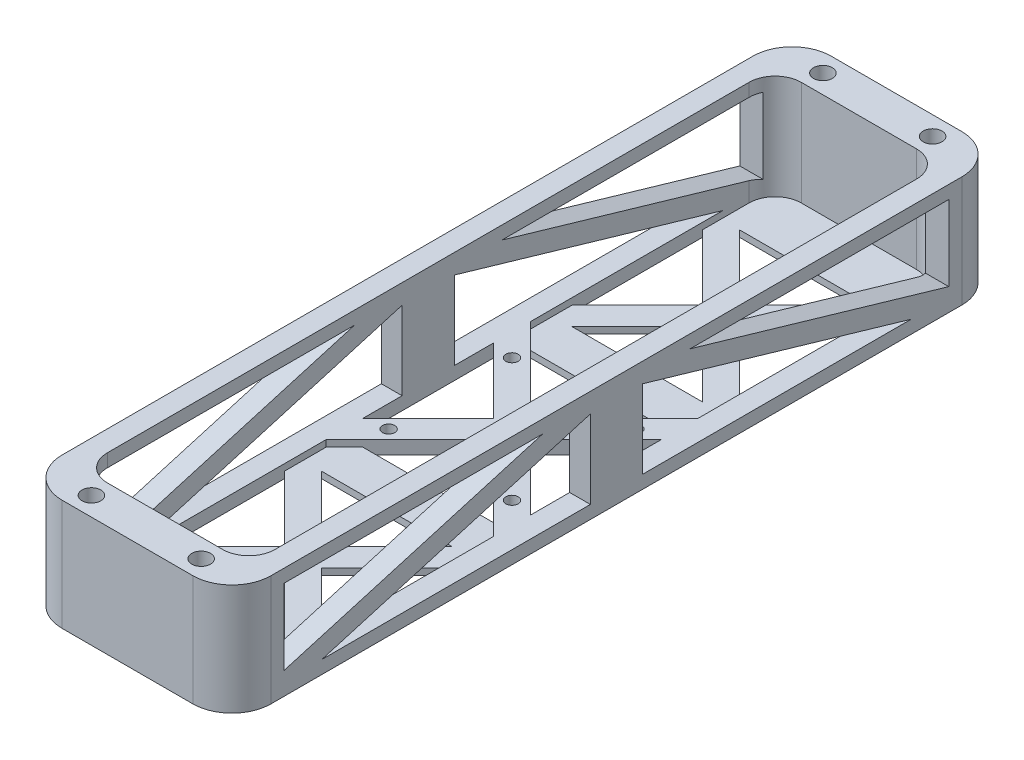
from build123d import *

# Parameters (mm, degrees)
SKETCH1_R            = 2.286
SKETCH1_R_2          = 1.5
BOSS_EXTRUDE1_DEPTH  = 1.5875
CUT_EXTRUDE1_REACH   = 145.693
SKETCH4_R            = 2.286
BOSS_EXTRUDE4_DEPTH  = 25.4
SKETCH16_R           = 1.5
BOSS_EXTRUDE6_DEPTH  = 1.5875
CUT_EXTRUDE13_DEPTH  = 23.8125
CUT_EXTRUDE15_REACH  = 166.863
CUT_EXTRUDE17_REACH  = 147.912
SKETCH20_W           = 50.8
SKETCH20_H           = 8.128
SKETCH20_W_2         = 8.128
SKETCH20_H_2         = 50.8
FILLET2_R            = 9.525
FILLET3_R            = 6.35
CUT_EXTRUDE18_DEPTH  = 118.872
BOSS_EXTRUDE7_DEPTH  = 1.5875
SKETCH23_W           = 5.034871939
SKETCH23_H           = 59.780256122
BOSS_EXTRUDE8_DEPTH  = 3.175
SKETCH24_W           = 59.780256122
SKETCH24_H           = 20.6375
BOSS_EXTRUDE9_DEPTH  = 5.034871939
SKETCH25_W           = 59.780256122
SKETCH25_H           = 20.6375
BOSS_EXTRUDE10_DEPTH = 5.034871939
CUT_EXTRUDE21_START  = -50.8
CUT_EXTRUDE21_DEPTH  = 50.8


with BuildPart() as part:
    # Sketch1 → Boss-Extrude1 (new body)
    with BuildSketch(Plane(origin=(0, 0, 0), x_dir=(1, 0, 0), z_dir=(0, 1, 0))):
        Polygon((-25.4, 101.6), (25.4, 101.6), (25.4, 25.4), (101.6, 25.4), (101.6, -25.4), (25.4, -25.4), (25.4, -101.6), (-25.4, -101.6), (-25.4, -25.4), (-101.6, -25.4), (-101.6, 25.4), (-25.4, 25.4), align=None)
        with Locations(Location((-13.335, 88.9, 0), (0, 0, 270))):
            Circle(SKETCH1_R, mode=Mode.SUBTRACT)
        with Locations(Location((13.335, 88.9, 0), (0, 0, 270))):
            Circle(SKETCH1_R, mode=Mode.SUBTRACT)
        with Locations(Location((-13.335, -88.9, 0), (0, 0, 270))):
            Circle(SKETCH1_R, mode=Mode.SUBTRACT)
        with Locations(Location((13.335, -88.9, 0), (0, 0, 270))):
            Circle(SKETCH1_R, mode=Mode.SUBTRACT)
        with Locations(Location((88.9, -13.335, 0), (0, 0, 270))):
            Circle(SKETCH1_R, mode=Mode.SUBTRACT)
        with Locations(Location((88.9, 13.335, 0), (0, 0, 270))):
            Circle(SKETCH1_R, mode=Mode.SUBTRACT)
        with Locations(Location((-88.9, 13.335, 0), (0, 0, 270))):
            Circle(SKETCH1_R, mode=Mode.SUBTRACT)
        with Locations(Location((-88.9, -13.335, 0), (0, 0, 270))):
            Circle(SKETCH1_R, mode=Mode.SUBTRACT)
        with Locations(Location((-15, 15, 0), (0, 0, 270))):
            Circle(SKETCH1_R_2, mode=Mode.SUBTRACT)
        with Locations(Location((15, 15, 0), (0, 0, 270))):
            Circle(SKETCH1_R_2, mode=Mode.SUBTRACT)
        with Locations(Location((15, -15, 0), (0, 0, 270))):
            Circle(SKETCH1_R_2, mode=Mode.SUBTRACT)
        with Locations(Location((-15, -15, 0), (0, 0, 270))):
            Circle(SKETCH1_R_2, mode=Mode.SUBTRACT)
    extrude(amount=BOSS_EXTRUDE1_DEPTH)

    # Sketch3 → Cut-Extrude1 (cut, up to next)
    with BuildSketch(Plane(origin=(0, 1.5875, 0), x_dir=(1, 0, 0), z_dir=(0, 1, 0)), mode=Mode.PRIVATE) as cut_extrude1_sk1:
        Polygon((15.875, 71.165128061), (0, 55.290128061), (-15.875, 71.165128061), align=None)
    cut_extrude1_tool1 = extrude(cut_extrude1_sk1.sketch, amount=-CUT_EXTRUDE1_REACH, mode=Mode.PRIVATE) & part.part
    # Sketch3 → Cut-Extrude1 (cut, up to next)
    with BuildSketch(Plane(origin=(0, 1.5875, 0), x_dir=(1, 0, 0), z_dir=(0, 1, 0)), mode=Mode.PRIVATE) as cut_extrude1_sk2:
        Polygon((-20.365128061, 66.675), (-4.490128061, 50.8), (-20.365128061, 34.925), align=None)
    cut_extrude1_tool2 = extrude(cut_extrude1_sk2.sketch, amount=-CUT_EXTRUDE1_REACH, mode=Mode.PRIVATE) & part.part
    # Sketch3 → Cut-Extrude1 (cut, up to next)
    with BuildSketch(Plane(origin=(0, 1.5875, 0), x_dir=(1, 0, 0), z_dir=(0, 1, 0)), mode=Mode.PRIVATE) as cut_extrude1_sk3:
        Polygon((-15.875, 30.434871939), (0, 46.309871939), (15.875, 30.434871939), align=None)
    cut_extrude1_tool3 = extrude(cut_extrude1_sk3.sketch, amount=-CUT_EXTRUDE1_REACH, mode=Mode.PRIVATE) & part.part
    # Sketch3 → Cut-Extrude1 (cut, up to next)
    with BuildSketch(Plane(origin=(0, 1.5875, 0), x_dir=(1, 0, 0), z_dir=(0, 1, 0)), mode=Mode.PRIVATE) as cut_extrude1_sk4:
        Polygon((20.365128061, 34.925), (4.490128061, 50.8), (20.365128061, 66.675), align=None)
    cut_extrude1_tool4 = extrude(cut_extrude1_sk4.sketch, amount=-CUT_EXTRUDE1_REACH, mode=Mode.PRIVATE) & part.part
    # Sketch3 → Cut-Extrude1 (cut, up to next)
    with BuildSketch(Plane(origin=(0, 1.5875, 0), x_dir=(1, 0, 0), z_dir=(0, 1, 0)), mode=Mode.PRIVATE) as cut_extrude1_sk5:
        Polygon((-34.925, 20.365128061), (-50.8, 4.490128061), (-66.675, 20.365128061), align=None)
    cut_extrude1_tool5 = extrude(cut_extrude1_sk5.sketch, amount=-CUT_EXTRUDE1_REACH, mode=Mode.PRIVATE) & part.part
    # Sketch3 → Cut-Extrude1 (cut, up to next)
    with BuildSketch(Plane(origin=(0, 1.5875, 0), x_dir=(1, 0, 0), z_dir=(0, 1, 0)), mode=Mode.PRIVATE) as cut_extrude1_sk6:
        Polygon((-71.165128061, 15.875), (-55.290128061, 0), (-71.165128061, -15.875), align=None)
    cut_extrude1_tool6 = extrude(cut_extrude1_sk6.sketch, amount=-CUT_EXTRUDE1_REACH, mode=Mode.PRIVATE) & part.part
    # Sketch3 → Cut-Extrude1 (cut, up to next)
    with BuildSketch(Plane(origin=(0, 1.5875, 0), x_dir=(1, 0, 0), z_dir=(0, 1, 0)), mode=Mode.PRIVATE) as cut_extrude1_sk7:
        Polygon((-66.675, -20.365128061), (-50.8, -4.490128061), (-34.925, -20.365128061), align=None)
    cut_extrude1_tool7 = extrude(cut_extrude1_sk7.sketch, amount=-CUT_EXTRUDE1_REACH, mode=Mode.PRIVATE) & part.part
    # Sketch3 → Cut-Extrude1 (cut, up to next)
    with BuildSketch(Plane(origin=(0, 1.5875, 0), x_dir=(1, 0, 0), z_dir=(0, 1, 0)), mode=Mode.PRIVATE) as cut_extrude1_sk8:
        Polygon((-30.434871939, -15.875), (-46.309871939, 0), (-30.434871939, 15.875), align=None)
    cut_extrude1_tool8 = extrude(cut_extrude1_sk8.sketch, amount=-CUT_EXTRUDE1_REACH, mode=Mode.PRIVATE) & part.part
    # Sketch3 → Cut-Extrude1 (cut, up to next)
    with BuildSketch(Plane(origin=(0, 1.5875, 0), x_dir=(1, 0, 0), z_dir=(0, 1, 0)), mode=Mode.PRIVATE) as cut_extrude1_sk9:
        Polygon((30.434871939, 15.875), (46.309871939, 0), (30.434871939, -15.875), align=None)
    cut_extrude1_tool9 = extrude(cut_extrude1_sk9.sketch, amount=-CUT_EXTRUDE1_REACH, mode=Mode.PRIVATE) & part.part
    # Sketch3 → Cut-Extrude1 (cut, up to next)
    with BuildSketch(Plane(origin=(0, 1.5875, 0), x_dir=(1, 0, 0), z_dir=(0, 1, 0)), mode=Mode.PRIVATE) as cut_extrude1_sk10:
        Polygon((66.675, 20.365128061), (50.8, 4.490128061), (34.925, 20.365128061), align=None)
    cut_extrude1_tool10 = extrude(cut_extrude1_sk10.sketch, amount=-CUT_EXTRUDE1_REACH, mode=Mode.PRIVATE) & part.part
    # Sketch3 → Cut-Extrude1 (cut, up to next)
    with BuildSketch(Plane(origin=(0, 1.5875, 0), x_dir=(1, 0, 0), z_dir=(0, 1, 0)), mode=Mode.PRIVATE) as cut_extrude1_sk11:
        Polygon((71.165128061, -15.875), (55.290128061, 0), (71.165128061, 15.875), align=None)
    cut_extrude1_tool11 = extrude(cut_extrude1_sk11.sketch, amount=-CUT_EXTRUDE1_REACH, mode=Mode.PRIVATE) & part.part
    # Sketch3 → Cut-Extrude1 (cut, up to next)
    with BuildSketch(Plane(origin=(0, 1.5875, 0), x_dir=(1, 0, 0), z_dir=(0, 1, 0)), mode=Mode.PRIVATE) as cut_extrude1_sk12:
        Polygon((34.925, -20.365128061), (50.8, -4.490128061), (66.675, -20.365128061), align=None)
    cut_extrude1_tool12 = extrude(cut_extrude1_sk12.sketch, amount=-CUT_EXTRUDE1_REACH, mode=Mode.PRIVATE) & part.part
    # Sketch3 → Cut-Extrude1 (cut, up to next)
    with BuildSketch(Plane(origin=(0, 1.5875, 0), x_dir=(1, 0, 0), z_dir=(0, 1, 0)), mode=Mode.PRIVATE) as cut_extrude1_sk13:
        Polygon((15.875, -30.434871939), (0, -46.309871939), (-15.875, -30.434871939), align=None)
    cut_extrude1_tool13 = extrude(cut_extrude1_sk13.sketch, amount=-CUT_EXTRUDE1_REACH, mode=Mode.PRIVATE) & part.part
    # Sketch3 → Cut-Extrude1 (cut, up to next)
    with BuildSketch(Plane(origin=(0, 1.5875, 0), x_dir=(1, 0, 0), z_dir=(0, 1, 0)), mode=Mode.PRIVATE) as cut_extrude1_sk14:
        Polygon((-20.365128061, -34.925), (-4.490128061, -50.8), (-20.365128061, -66.675), align=None)
    cut_extrude1_tool14 = extrude(cut_extrude1_sk14.sketch, amount=-CUT_EXTRUDE1_REACH, mode=Mode.PRIVATE) & part.part
    # Sketch3 → Cut-Extrude1 (cut, up to next)
    with BuildSketch(Plane(origin=(0, 1.5875, 0), x_dir=(1, 0, 0), z_dir=(0, 1, 0)), mode=Mode.PRIVATE) as cut_extrude1_sk15:
        Polygon((20.365128061, -66.675), (4.490128061, -50.8), (20.365128061, -34.925), align=None)
    cut_extrude1_tool15 = extrude(cut_extrude1_sk15.sketch, amount=-CUT_EXTRUDE1_REACH, mode=Mode.PRIVATE) & part.part
    # Sketch3 → Cut-Extrude1 (cut, up to next)
    with BuildSketch(Plane(origin=(0, 1.5875, 0), x_dir=(1, 0, 0), z_dir=(0, 1, 0)), mode=Mode.PRIVATE) as cut_extrude1_sk16:
        Polygon((-15.875, -71.165128061), (0, -55.290128061), (15.875, -71.165128061), align=None)
    cut_extrude1_tool16 = extrude(cut_extrude1_sk16.sketch, amount=-CUT_EXTRUDE1_REACH, mode=Mode.PRIVATE) & part.part
    # Sketch3 → Cut-Extrude1 (cut, up to next)
    with BuildSketch(Plane(origin=(0, 1.5875, 0), x_dir=(1, 0, 0), z_dir=(0, 1, 0)), mode=Mode.PRIVATE) as cut_extrude1_sk17:
        Polygon((0, 4.490128061), (-15.875, 20.365128061), (15.875, 20.365128061), align=None)
    cut_extrude1_tool17 = extrude(cut_extrude1_sk17.sketch, amount=-CUT_EXTRUDE1_REACH, mode=Mode.PRIVATE) & part.part
    # Sketch3 → Cut-Extrude1 (cut, up to next)
    with BuildSketch(Plane(origin=(0, 1.5875, 0), x_dir=(1, 0, 0), z_dir=(0, 1, 0)), mode=Mode.PRIVATE) as cut_extrude1_sk18:
        Polygon((-4.490128061, 0), (-20.365128061, -15.875), (-20.365128061, 15.875), align=None)
    cut_extrude1_tool18 = extrude(cut_extrude1_sk18.sketch, amount=-CUT_EXTRUDE1_REACH, mode=Mode.PRIVATE) & part.part
    # Sketch3 → Cut-Extrude1 (cut, up to next)
    with BuildSketch(Plane(origin=(0, 1.5875, 0), x_dir=(1, 0, 0), z_dir=(0, 1, 0)), mode=Mode.PRIVATE) as cut_extrude1_sk19:
        Polygon((-15.875, -20.365128061), (0, -4.490128061), (15.875, -20.365128061), align=None)
    cut_extrude1_tool19 = extrude(cut_extrude1_sk19.sketch, amount=-CUT_EXTRUDE1_REACH, mode=Mode.PRIVATE) & part.part
    # Sketch3 → Cut-Extrude1 (cut, up to next)
    with BuildSketch(Plane(origin=(0, 1.5875, 0), x_dir=(1, 0, 0), z_dir=(0, 1, 0)), mode=Mode.PRIVATE) as cut_extrude1_sk20:
        Polygon((20.365128061, 15.875), (20.365128061, -15.875), (4.490128061, 0), align=None)
    cut_extrude1_tool20 = extrude(cut_extrude1_sk20.sketch, amount=-CUT_EXTRUDE1_REACH, mode=Mode.PRIVATE) & part.part
    add(cut_extrude1_tool1.solids().sort_by_distance((0, 1.5875, -65.873461))[0], mode=Mode.SUBTRACT)
    add(cut_extrude1_tool2.solids().sort_by_distance((-15.073461, 1.5875, -50.8))[0], mode=Mode.SUBTRACT)
    add(cut_extrude1_tool3.solids().sort_by_distance((0, 1.5875, -35.726539))[0], mode=Mode.SUBTRACT)
    add(cut_extrude1_tool4.solids().sort_by_distance((15.073461, 1.5875, -50.8))[0], mode=Mode.SUBTRACT)
    add(cut_extrude1_tool5.solids().sort_by_distance((-50.8, 1.5875, -15.073461))[0], mode=Mode.SUBTRACT)
    add(cut_extrude1_tool6.solids().sort_by_distance((-65.873461, 1.5875, 0))[0], mode=Mode.SUBTRACT)
    add(cut_extrude1_tool7.solids().sort_by_distance((-50.8, 1.5875, 15.073461))[0], mode=Mode.SUBTRACT)
    add(cut_extrude1_tool8.solids().sort_by_distance((-35.726539, 1.5875, 0))[0], mode=Mode.SUBTRACT)
    add(cut_extrude1_tool9.solids().sort_by_distance((35.726539, 1.5875, 0))[0], mode=Mode.SUBTRACT)
    add(cut_extrude1_tool10.solids().sort_by_distance((50.8, 1.5875, -15.073461))[0], mode=Mode.SUBTRACT)
    add(cut_extrude1_tool11.solids().sort_by_distance((65.873461, 1.5875, 0))[0], mode=Mode.SUBTRACT)
    add(cut_extrude1_tool12.solids().sort_by_distance((50.8, 1.5875, 15.073461))[0], mode=Mode.SUBTRACT)
    add(cut_extrude1_tool13.solids().sort_by_distance((0, 1.5875, 35.726539))[0], mode=Mode.SUBTRACT)
    add(cut_extrude1_tool14.solids().sort_by_distance((-15.073461, 1.5875, 50.8))[0], mode=Mode.SUBTRACT)
    add(cut_extrude1_tool15.solids().sort_by_distance((15.073461, 1.5875, 50.8))[0], mode=Mode.SUBTRACT)
    add(cut_extrude1_tool16.solids().sort_by_distance((0, 1.5875, 65.873461))[0], mode=Mode.SUBTRACT)
    add(cut_extrude1_tool17.solids().sort_by_distance((0, 1.5875, -15.073461))[0], mode=Mode.SUBTRACT)
    add(cut_extrude1_tool18.solids().sort_by_distance((-15.073461, 1.5875, 0))[0], mode=Mode.SUBTRACT)
    add(cut_extrude1_tool19.solids().sort_by_distance((0, 1.5875, 15.073461))[0], mode=Mode.SUBTRACT)
    add(cut_extrude1_tool20.solids().sort_by_distance((15.073461, 1.5875, 0))[0], mode=Mode.SUBTRACT)

    # Sketch4 → Boss-Extrude4 (add)
    with BuildSketch(Plane(origin=(0, 1.5875, 0), x_dir=(1, 0, 0), z_dir=(0, 1, 0))):
        Polygon((-93.472, 25.4), (-93.472, 13.335), (-93.472, -13.335), (-93.472, -25.4), (-84.328, -25.4), (-25.4, -25.4), (-25.4, -84.328), (-25.4, -93.472), (-13.335, -93.472), (13.335, -93.472), (25.4, -93.472), (25.4, -84.328), (25.4, -25.4), (84.328, -25.4), (93.472, -25.4), (93.472, -13.335), (93.472, 13.335), (93.472, 25.4), (84.328, 25.4), (25.4, 25.4), (25.4, 84.328), (25.4, 93.472), (13.335, 93.472), (-13.335, 93.472), (-25.4, 93.472), (-25.4, 84.328), (-25.4, 25.4), (-84.328, 25.4), align=None)
        with Locations(Location((-13.335, -88.9, 0), (0, 0, 270))):
            Circle(SKETCH4_R, mode=Mode.SUBTRACT)
        with Locations(Location((-88.9, -13.335, 0), (0, 0, 270))):
            Circle(SKETCH4_R, mode=Mode.SUBTRACT)
        with Locations(Location((13.335, -88.9, 0), (0, 0, 270))):
            Circle(SKETCH4_R, mode=Mode.SUBTRACT)
        with Locations(Location((88.9, -13.335, 0), (0, 0, 270))):
            Circle(SKETCH4_R, mode=Mode.SUBTRACT)
        with Locations(Location((-88.9, 13.335, 0), (0, 0, 270))):
            Circle(SKETCH4_R, mode=Mode.SUBTRACT)
        with Locations(Location((-13.335, 88.9, 0), (0, 0, 270))):
            Circle(SKETCH4_R, mode=Mode.SUBTRACT)
        Polygon((84.328, 20.365128061), (84.328, 13.335), (84.328, -13.335), (84.328, -20.365128061), (66.675, -20.365128061), (34.925, -20.365128061), (25.4, -20.365128061), (20.365128061, -20.365128061), (20.365128061, -25.4), (20.365128061, -34.925), (20.365128061, -66.675), (20.365128061, -84.328), (13.335, -84.328), (-13.335, -84.328), (-20.365128061, -84.328), (-20.365128061, -66.675), (-20.365128061, -34.925), (-20.365128061, -25.4), (-20.365128061, -20.365128061), (-25.4, -20.365128061), (-34.925, -20.365128061), (-66.675, -20.365128061), (-84.328, -20.365128061), (-84.328, -13.335), (-84.328, 13.335), (-84.328, 20.365128061), (-66.675, 20.365128061), (-34.925, 20.365128061), (-25.4, 20.365128061), (-20.365128061, 20.365128061), (-20.365128061, 25.4), (-20.365128061, 34.925), (-20.365128061, 66.675), (-20.365128061, 84.328), (-13.335, 84.328), (13.335, 84.328), (20.365128061, 84.328), (20.365128061, 66.675), (20.365128061, 34.925), (20.365128061, 25.4), (20.365128061, 20.365128061), (25.4, 20.365128061), (34.925, 20.365128061), (66.675, 20.365128061), align=None, mode=Mode.SUBTRACT)
        with Locations(Location((88.9, 13.335, 0), (0, 0, 270))):
            Circle(SKETCH4_R, mode=Mode.SUBTRACT)
        with Locations(Location((13.335, 88.9, 0), (0, 0, 270))):
            Circle(SKETCH4_R, mode=Mode.SUBTRACT)
    extrude(amount=BOSS_EXTRUDE4_DEPTH)

    # Sketch16 → Boss-Extrude6 (add)
    with BuildSketch(Plane(origin=(0, 1.5875, 0), x_dir=(1, 0, 0), z_dir=(0, 1, 0))):
        Polygon((20.365128061, 24.855256121), (15.875, 20.365128061), (0, 4.490128061), (-15.875, 20.365128061), (-20.365128061, 24.855256121), (-20.365128061, 20.365128061), (-24.855256121, 20.365128061), (-20.365128061, 15.875), (-4.490128061, 0), (-20.365128061, -15.875), (-24.855256121, -20.365128061), (-20.365128061, -20.365128061), (-20.365128061, -24.855256121), (-15.875, -20.365128061), (0, -4.490128061), (15.875, -20.365128061), (20.365128061, -24.855256121), (20.365128061, -20.365128061), (24.855256121, -20.365128061), (20.365128061, -15.875), (4.490128061, 0), (20.365128061, 15.875), (24.855256121, 20.365128061), (20.365128061, 20.365128061), align=None)
        with Locations((-15, -15)):
            Circle(SKETCH16_R, mode=Mode.SUBTRACT)
        with Locations((15, -15)):
            Circle(SKETCH16_R, mode=Mode.SUBTRACT)
        with Locations((-15, 15)):
            Circle(SKETCH16_R, mode=Mode.SUBTRACT)
        with Locations((15, 15)):
            Circle(SKETCH16_R, mode=Mode.SUBTRACT)
    extrude(amount=BOSS_EXTRUDE6_DEPTH)

    # Sketch17 → Cut-Extrude13 (cut)
    with BuildSketch(Plane(origin=(0, 26.9875, 0), x_dir=(1, 0, 0), z_dir=(0, 1, 0))):
        Polygon((-25.4, 25.4), (-29.890128061, 25.4), (-24.855256121, 20.365128061), (-20.365128061, 20.365128061), (-20.365128061, 24.855256121), (-25.4, 29.890128061), align=None)
        Polygon((20.365128061, 20.365128061), (24.855256121, 20.365128061), (29.890128061, 25.4), (25.4, 25.4), (25.4, 29.890128061), (20.365128061, 24.855256121), align=None)
        Polygon((20.365128061, -24.855256121), (25.4, -29.890128061), (25.4, -25.4), (29.890128061, -25.4), (24.855256121, -20.365128061), (20.365128061, -20.365128061), align=None)
        Polygon((-29.890128061, -25.4), (-25.4, -25.4), (-25.4, -29.890128061), (-20.365128061, -24.855256121), (-20.365128061, -20.365128061), (-24.855256121, -20.365128061), align=None)
        Polygon((-24.855256121, 20.365128061), (-29.890128061, 25.4), (-29.890128061, 20.365128061), align=None)
        Polygon((-20.365128061, 29.890128061), (-25.4, 29.890128061), (-20.365128061, 24.855256121), align=None)
        Polygon((20.365128061, 29.890128061), (20.365128061, 24.855256121), (25.4, 29.890128061), align=None)
        Polygon((29.890128061, 25.4), (24.855256121, 20.365128061), (29.890128061, 20.365128061), align=None)
        Polygon((24.855256121, -20.365128061), (29.890128061, -25.4), (29.890128061, -20.365128061), align=None)
        Polygon((20.365128061, -29.890128061), (25.4, -29.890128061), (20.365128061, -24.855256121), align=None)
        Polygon((-20.365128061, -24.855256121), (-25.4, -29.890128061), (-20.365128061, -29.890128061), align=None)
        Polygon((-29.890128061, -20.365128061), (-29.890128061, -25.4), (-24.855256121, -20.365128061), align=None)
    extrude(amount=-CUT_EXTRUDE13_DEPTH, mode=Mode.SUBTRACT)

    # Cut-Extrude15: up to this face of the body (flat: up to its plane)
    cut_extrude15_end = Plane(part.part.faces().sort_by_distance((61.668110408, 13.302359509, -25.4))[0])
    # Sketch18 → Cut-Extrude15 (cut, up to the picked face)
    with BuildSketch(Plane.XY.offset(25.4), mode=Mode.PRIVATE) as cut_extrude15_sk1:
        with BuildLine():
            add(Edge.make_bspline(
                [(-77.978, 26.9875), (-53.933199385, 9.774034089), (-29.890128061, 3.175)],
                knots=[0, 0, 0, 0.308317682, 0.308317682, 0.308317682], degree=2))
            Line((-29.890128061, 3.175), (-29.890128061, 26.9875))
            Line((-29.890128061, 26.9875), (-77.978, 26.9875))
        make_face()
    cut_extrude15_tool1 = split(extrude(cut_extrude15_sk1.sketch, amount=-CUT_EXTRUDE15_REACH, mode=Mode.PRIVATE), bisect_by=cut_extrude15_end, keep=Keep.BOTH, mode=Mode.PRIVATE)
    cut_extrude15 = cut_extrude15_tool1.solids().sort_by(Axis((-46.956117, 18.399328, 25.4), (0, 0, -1)))[0]
    add(cut_extrude15, mode=Mode.SUBTRACT)

    # Sketch20 → Cut-Extrude17 (cut, up to next)
    with BuildSketch(Plane(origin=(0, 1.5875, 0), x_dir=(1, 0, 0), z_dir=(0, 1, 0)), mode=Mode.PRIVATE) as cut_extrude17_sk1:
        with Locations((0, 97.536)):
            Rectangle(SKETCH20_W, SKETCH20_H)
    cut_extrude17_tool1 = extrude(cut_extrude17_sk1.sketch, amount=-CUT_EXTRUDE17_REACH, mode=Mode.PRIVATE) & part.part
    # Sketch20 → Cut-Extrude17 (cut, up to next)
    with BuildSketch(Plane(origin=(0, 1.5875, 0), x_dir=(1, 0, 0), z_dir=(0, 1, 0)), mode=Mode.PRIVATE) as cut_extrude17_sk2:
        with Locations((-97.536, 0)):
            Rectangle(SKETCH20_W_2, SKETCH20_H_2)
    cut_extrude17_tool2 = extrude(cut_extrude17_sk2.sketch, amount=-CUT_EXTRUDE17_REACH, mode=Mode.PRIVATE) & part.part
    # Sketch20 → Cut-Extrude17 (cut, up to next)
    with BuildSketch(Plane(origin=(0, 1.5875, 0), x_dir=(1, 0, 0), z_dir=(0, 1, 0)), mode=Mode.PRIVATE) as cut_extrude17_sk3:
        with Locations((0, -97.536)):
            Rectangle(SKETCH20_W, SKETCH20_H)
    cut_extrude17_tool3 = extrude(cut_extrude17_sk3.sketch, amount=-CUT_EXTRUDE17_REACH, mode=Mode.PRIVATE) & part.part
    # Sketch20 → Cut-Extrude17 (cut, up to next)
    with BuildSketch(Plane(origin=(0, 1.5875, 0), x_dir=(1, 0, 0), z_dir=(0, 1, 0)), mode=Mode.PRIVATE) as cut_extrude17_sk4:
        with Locations((97.536, 0)):
            Rectangle(SKETCH20_W_2, SKETCH20_H_2)
    cut_extrude17_tool4 = extrude(cut_extrude17_sk4.sketch, amount=-CUT_EXTRUDE17_REACH, mode=Mode.PRIVATE) & part.part
    add(cut_extrude17_tool1.solids().sort_by_distance((0, 1.5875, -97.536))[0], mode=Mode.SUBTRACT)
    add(cut_extrude17_tool2.solids().sort_by_distance((-97.536, 1.5875, 0))[0], mode=Mode.SUBTRACT)
    add(cut_extrude17_tool3.solids().sort_by_distance((0, 1.5875, 97.536))[0], mode=Mode.SUBTRACT)
    add(cut_extrude17_tool4.solids().sort_by_distance((97.536, 1.5875, 0))[0], mode=Mode.SUBTRACT)

    # Fillet2
    fillet2_edges = [part.edges().sort_by_distance(p)[0] for p in [
        (-25.4, 13.49375, 93.472),
        (25.4, 13.49375, 93.472),
        (93.472, 13.49375, 25.4),
        (93.472, 13.49375, -25.4),
        (25.4, 13.49375, -93.472),
        (-25.4, 13.49375, -93.472),
        (-93.472, 13.49375, -25.4),
        (-93.472, 13.49375, 25.4),
    ]]
    fillet(fillet2_edges, radius=FILLET2_R)

    # Fillet3
    fillet3_edges = [part.edges().sort_by_distance(p)[0] for p in [
        (84.328, 14.2875, -20.365128061),
        (84.328, 14.2875, 20.365128061),
        (20.365128061, 14.2875, 84.328),
        (-20.365128061, 14.2875, 84.328),
        (-84.328, 14.2875, 20.365128061),
        (-84.328, 14.2875, -20.365128061),
        (-20.365128061, 14.2875, -84.328),
        (20.365128061, 14.2875, -84.328),
    ]]
    fillet(fillet3_edges, radius=FILLET3_R)

    # Mirror1: Cut-Extrude15 across plane
    add(cut_extrude15.mirror(Plane(origin=(0, 0, 0), x_dir=(0, 0, 1), z_dir=(1, 0, 0))), mode=Mode.SUBTRACT)

    # Sketch21 → Cut-Extrude18 (cut)
    with BuildSketch(Plane.XY.offset(93.472)):
        with BuildLine():
            Line((93.472, 26.9875), (83.947, 26.9875))
            Line((83.947, 26.9875), (77.978, 26.9875))
            add(Edge.make_bspline(
                [(77.978, 26.9875), (53.933199385, 9.774034089), (29.890128061, 3.175)],
                knots=[0, 0, 0, 1, 1, 1], degree=2))
            Line((29.890128061, 3.175), (25.4, 3.175))
            Line((25.4, 3.175), (25.4, 0))
            Line((25.4, 0), (83.947, 0))
            Line((83.947, 0), (93.472, 0))
            Line((93.472, 0), (93.472, 26.9875))
        make_face()
        with BuildLine():
            Line((-83.947, 26.9875), (-93.472, 26.9875))
            Line((-93.472, 26.9875), (-93.472, 0))
            Line((-93.472, 0), (-83.947, 0))
            Line((-83.947, 0), (-25.4, 0))
            Line((-25.4, 0), (-25.4, 3.175))
            Line((-25.4, 3.175), (-29.890128061, 3.175))
            add(Edge.make_bspline(
                [(-29.890128061, 3.175), (-53.933199385, 9.774034089), (-77.978, 26.9875)],
                knots=[0, 0, 0, 1, 1, 1], degree=2))
            Line((-77.978, 26.9875), (-83.947, 26.9875))
        make_face()
    extrude(amount=-CUT_EXTRUDE18_DEPTH, mode=Mode.SUBTRACT)

    # Sketch22 → Boss-Extrude7 (add)
    with BuildSketch(Plane(origin=(0, 1.5875, 0), x_dir=(1, 0, 0), z_dir=(0, 1, 0))):
        Polygon((25.4, -20.365128061), (25.4, 20.365128061), (24.855256121, 20.365128061), (20.365128061, 15.875), (20.365128061, -15.875), (24.855256121, -20.365128061), align=None)
        Polygon((-25.4, 20.365128061), (-25.4, -20.365128061), (-24.855256121, -20.365128061), (-20.365128061, -15.875), (-20.365128061, 15.875), (-24.855256121, 20.365128061), align=None)
    extrude(amount=BOSS_EXTRUDE7_DEPTH)

    # Sketch23 → Boss-Extrude8 (add)
    with BuildSketch(Plane(origin=(0, 3.175, 0), x_dir=(1, 0, 0), z_dir=(0, 1, 0))):
        with Locations((22.88256403, 0)):
            Rectangle(SKETCH23_W, SKETCH23_H)
        with Locations((-22.88256403, 0)):
            Rectangle(SKETCH23_W, SKETCH23_H)
    extrude(amount=BOSS_EXTRUDE8_DEPTH)

    # Sketch24 → Boss-Extrude9 (add)
    with BuildSketch(Plane.ZY.offset(25.4)):
        with Locations((0, 16.66875)):
            Rectangle(SKETCH24_W, SKETCH24_H)
    extrude(amount=-BOSS_EXTRUDE9_DEPTH)

    # Sketch25 → Boss-Extrude10 (add)
    with BuildSketch(Plane(origin=(25.4, 0, 0), x_dir=(0, 0, -1), z_dir=(1, 0, 0))):
        with Locations((0, 16.66875)):
            Rectangle(SKETCH25_W, SKETCH25_H)
    extrude(amount=-BOSS_EXTRUDE10_DEPTH)

    # Sketch28 → Cut-Extrude21 (cut)
    with BuildSketch(Plane.ZY.offset(25.4).offset(CUT_EXTRUDE21_START)):
        Polygon((-80.772, 23.8125), (-80.772, 5.46568924), (-17.909436674, 23.8125), align=None)
        Polygon((-6.35, 22.225), (-71.621934564, 3.175), (-6.35, 3.175), align=None)
        Polygon((71.621934564, 3.175), (6.35, 22.225), (6.35, 3.175), align=None)
        Polygon((80.772, 23.8125), (17.909436674, 23.8125), (80.772, 5.46568924), align=None)
    cut_extrude21 = extrude(amount=CUT_EXTRUDE21_DEPTH, mode=Mode.SUBTRACT)

    # Mirror4: Cut-Extrude21 across plane
    add(cut_extrude21.mirror(Plane(origin=(0, 0, 0), x_dir=(0, 0, 1), z_dir=(1, 0, 0))), mode=Mode.SUBTRACT)


solid = part.part
